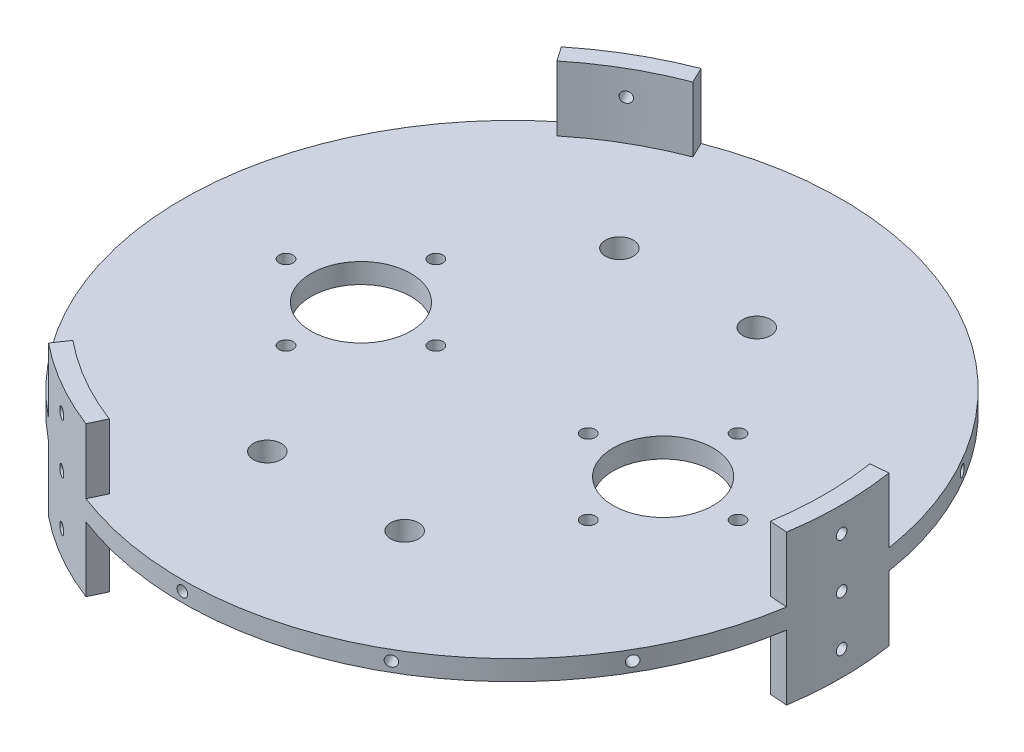
from build123d import *

# Parameters (mm, degrees)
SKETCH1_W                                     = 127.635
SKETCH1_H                                     = 127.635
MAIN_PLATE_DEPTH                              = 12.7
SKETCH9_R                                     = 85.725
BOSS_EXTRUDE1_DEPTH                           = 12.7
SKETCH10_R                                    = 97.039626961
SKETCH10_R_2                                  = 83.82
CUT_EXTRUDE1_DEPTH                            = 167.64
SKETCH18_R                                    = 83.82
SKETCH18_R_2                                  = 79.375
BOSS_EXTRUDE2_DEPTH                           = 19.05
SKETCH15_R                                    = 1.35255
CUT_EXTRUDE3_DEPTH                            = 15.24
CIRPATTERN1_COUNT                             = 12
SKETCH21_R                                    = 12.7
SKETCH21_R_2                                  = 1.778
CO2_MOUNTS_DEPTH                              = 26.4000001
SKETCH22_R                                    = 3.556
CUT_EXTRUDE5_DEPTH                            = 26.4000001
SKETCH23_R                                    = 79.375
CUT_EXTRUDE6_DEPTH                            = 12.7
USED_TO_VARY_PLATE_WIDTH_IN_DESIN_STUDY_DEPTH = 3.81


with BuildPart() as part:
    # Sketch1 → Main Plate (new body)
    with BuildSketch(Plane(origin=(0, 0, 0), x_dir=(1, 0, 0), z_dir=(0, 1, 0))):
        with Locations((63.8175, 63.8175)):
            Rectangle(SKETCH1_W, SKETCH1_H)
    extrude(amount=MAIN_PLATE_DEPTH)

    # Sketch9 → Boss-Extrude1 (add)
    with BuildSketch(Plane(origin=(0, 12.7, 0), x_dir=(1, 0, 0), z_dir=(0, 1, 0))):
        with Locations((63.8175, 63.8175)):
            Circle(SKETCH9_R)
    extrude(amount=-BOSS_EXTRUDE1_DEPTH)

    # Sketch10 → Cut-Extrude1 (cut)
    with BuildSketch(Plane(origin=(0, 12.7, 0), x_dir=(1, 0, 0), z_dir=(0, 1, 0))):
        with Locations((63.8175, 63.8175)):
            Circle(SKETCH10_R)
        with Locations((63.8175, 63.8175)):
            Circle(SKETCH10_R_2, mode=Mode.SUBTRACT)
    extrude(amount=-CUT_EXTRUDE1_DEPTH, mode=Mode.SUBTRACT)

    # Sketch18 → Boss-Extrude2 (add, symmetric)
    with BuildSketch(Plane(origin=(0, 6.35, 0), x_dir=(1, 0, 0), z_dir=(0, 1, 0))):
        with Locations((63.8175, 63.8175)):
            Circle(SKETCH18_R)
        with Locations((63.8175, 63.8175)):
            Circle(SKETCH18_R_2, mode=Mode.SUBTRACT)
    extrude(amount=BOSS_EXTRUDE2_DEPTH, both=True)

    # Sketch15 → Cut-Extrude3 (cut)
    with BuildSketch(Plane.ZY.offset(20.0025)):
        with Locations((-63.8175, 6.35)):
            Circle(SKETCH15_R)
        with Locations((-63.8175, 19.05)):
            Circle(SKETCH15_R)
        with Locations((-63.8175, -6.35)):
            Circle(SKETCH15_R)
    cut_extrude3 = extrude(amount=-CUT_EXTRUDE3_DEPTH, mode=Mode.SUBTRACT)

    # CirPattern1: Cut-Extrude3 ×12 about axis
    cirpattern1_axis = Axis((63.8175, 0, -63.8175), (0, 1, 0))
    for i in range(1, CIRPATTERN1_COUNT):
        add(cut_extrude3.rotate(cirpattern1_axis, i * 360 / CIRPATTERN1_COUNT), mode=Mode.SUBTRACT)

    # Sketch21 → CO2 Mounts (cut, through all)
    with BuildSketch(Plane(origin=(0, 12.7, 0), x_dir=(1, 0, 0), z_dir=(0, 1, 0))):
        with Locations((102.235, 63.8175)):
            Circle(SKETCH21_R)
        with Locations((102.235, 82.8675)):
            Circle(SKETCH21_R_2)
        with Locations((25.4, 63.8175)):
            Circle(SKETCH21_R)
        with Locations((121.285, 63.8175)):
            Circle(SKETCH21_R_2)
        with Locations((102.235, 44.7675)):
            Circle(SKETCH21_R_2)
        with Locations((83.185, 63.8175)):
            Circle(SKETCH21_R_2)
        with Locations((25.4, 82.8675)):
            Circle(SKETCH21_R_2)
        with Locations((6.35, 63.8175)):
            Circle(SKETCH21_R_2)
        with Locations((25.4, 44.7675)):
            Circle(SKETCH21_R_2)
        with Locations((44.45, 63.8175)):
            Circle(SKETCH21_R_2)
    extrude(amount=-CO2_MOUNTS_DEPTH, mode=Mode.SUBTRACT)

    # Sketch22 → Cut-Extrude5 (cut, through all)
    with BuildSketch(Plane(origin=(0, 12.7, 0), x_dir=(1, 0, 0), z_dir=(0, 1, 0))):
        with Locations((46.355, 108.585)):
            Circle(SKETCH22_R)
        with Locations((81.28, 108.585)):
            Circle(SKETCH22_R)
        with Locations((81.28, 19.05)):
            Circle(SKETCH22_R)
        with Locations((46.355, 19.05)):
            Circle(SKETCH22_R)
    extrude(amount=-CUT_EXTRUDE5_DEPTH, mode=Mode.SUBTRACT)

    # Sketch23 → Cut-Extrude6 (cut)
    with BuildSketch(Plane(origin=(0, 12.7, 0), x_dir=(1, 0, 0), z_dir=(0, 1, 0))):
        with Locations((63.8175, 63.8175)):
            Circle(SKETCH23_R)
        with BuildLine():
            Line((13.678739997, 125.352005526), (7.552270878, 134.237860218))
            Line((7.552270878, 134.237860218), (-19.267108419, 125.320629884))
            Line((-19.267108419, 125.320629884), (-48.79695837, 60.397770071))
            Line((-48.79695837, 60.397770071), (-9.884344094, 7.052469015))
            Line((-9.884344094, 7.052469015), (6.959175986, -7.46308736))
            Line((6.959175986, -7.46308736), (13.678739997, 2.282994474))
            ThreePointArc((13.678739997, 2.282994474), (-15.5575, 63.8175), (13.678739997, 125.352005526))
        make_face()
        with BuildLine():
            Line((142.177324996, 76.471687114), (152.935935453, 77.334437661))
            Line((152.935935453, 77.334437661), (158.623077101, 105.019316613))
            Line((158.623077101, 105.019316613), (117.163156193, 163.054346747))
            Line((117.163156193, 163.054346747), (51.508463168, 156.027684783))
            Line((51.508463168, 156.027684783), (30.515862556, 148.698546693))
            Line((30.515862556, 148.698546693), (35.596435007, 138.00619264))
            ThreePointArc((35.596435007, 138.00619264), (103.505, 132.558266425), (142.177324996, 76.471687114))
        make_face()
        with BuildLine():
            Line((35.596435007, -10.37119264), (30.964293669, -20.119797879))
            Line((30.964293669, -20.119797879), (52.096531318, -38.887446496))
            Line((52.096531318, -38.887446496), (123.086302178, -31.999616818))
            Line((123.086302178, -31.999616818), (149.828380926, 28.372346201))
            Line((149.828380926, 28.372346201), (153.977461458, 50.217040667))
            Line((153.977461458, 50.217040667), (142.177324996, 51.163312886))
            ThreePointArc((142.177324996, 51.163312886), (103.505, -4.923266425), (35.596435007, -10.37119264))
        make_face()
    cut_extrude6 = extrude(amount=CUT_EXTRUDE6_DEPTH, mode=Mode.SUBTRACT)

    # Mirror1: Cut-Extrude6 across plane
    add(cut_extrude6.mirror(Plane.ZX.offset(6.35)), mode=Mode.SUBTRACT)

    # Sketch25 → used to vary plate width in desin study (cut)
    with BuildSketch(Plane.XZ):
        with BuildLine():
            Line((35.596435007, -138.00619264), (33.682948073, -142.033234863))
            ThreePointArc((33.682948073, -142.033234863), (105.7275, -136.407749345), (146.621589331, -76.828079931))
            Line((146.621589331, -76.828079931), (142.177324996, -76.471687114))
            ThreePointArc((142.177324996, -76.471687114), (143.1925, -63.8175), (142.177324996, -51.163312886))
            Line((142.177324996, -51.163312886), (146.621589331, -50.806920069))
            ThreePointArc((146.621589331, -50.806920069), (105.7275, 8.772749345), (33.682948073, 14.398234863))
            Line((33.682948073, 14.398234863), (35.596435007, 10.37119264))
            ThreePointArc((35.596435007, 10.37119264), (24.13, 4.923266425), (13.678739997, -2.282994474))
            Line((13.678739997, -2.282994474), (11.147962597, 1.387654932))
            ThreePointArc((11.147962597, 1.387654932), (-20.0025, -63.8175), (11.147962597, -129.022654932))
            Line((11.147962597, -129.022654932), (13.678739997, -125.352005526))
            ThreePointArc((13.678739997, -125.352005526), (24.13, -132.558266425), (35.596435007, -138.00619264))
        make_face()
    used_to_vary_plate_width_in_desin_study = extrude(amount=-USED_TO_VARY_PLATE_WIDTH_IN_DESIN_STUDY_DEPTH, mode=Mode.SUBTRACT)

    # Mirror of previous cut: used to vary plate width in desin study across plane
    add(used_to_vary_plate_width_in_desin_study.mirror(Plane.ZX.offset(6.35)), mode=Mode.SUBTRACT)


solid = part.part
